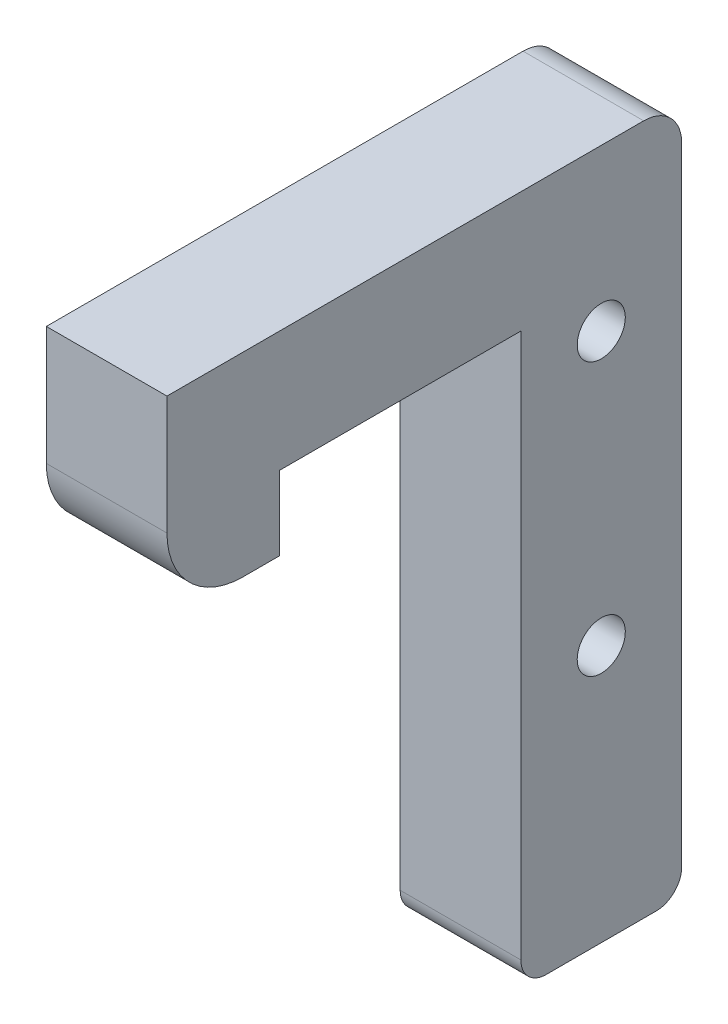
from build123d import *

# Parameters (mm, degrees)
SKETCH1_W                 = 9.525
SKETCH1_H                 = 9.525
EXTRUDE1_DEPTH            = 40.64
SKETCH3_W                 = 9.525
SKETCH3_H                 = 8.89
EXTRUDE2_DEPTH            = 5.842
FILLET1_R                 = 6
SKETCH4_W                 = 9.525
SKETCH4_H                 = 12.7
EXTRUDE3_DEPTH            = 45
FILLET2_R                 = 3
F_6_CLEARANCE_HOLE1_D     = 3.7973
F_6_CLEARANCE_HOLE1_DEPTH = 9.906
F_6_CLEARANCE_HOLE1_TIP   = 1.140824014
F_6_CLEARANCE_HOLE3_D     = 3.7973
F_6_CLEARANCE_HOLE3_DEPTH = 24.892
F_6_CLEARANCE_HOLE3_TIP   = 1.140824014
F_6_CLEARANCE_HOLE4_D     = 3.7973
F_6_CLEARANCE_HOLE4_DEPTH = 29.972
F_6_CLEARANCE_HOLE4_TIP   = 1.140824014
FILLET3_R                 = 2


with BuildPart() as part:
    # Sketch1 → Extrude1 (new body)
    with BuildSketch(Plane.XY):
        with Locations((-4.7625, 4.7625)):
            Rectangle(SKETCH1_W, SKETCH1_H)
    extrude(amount=EXTRUDE1_DEPTH)

    # Sketch3 → Extrude2 (add)
    with BuildSketch(Plane.XZ):
        with Locations((-4.7625, 36.195)):
            Rectangle(SKETCH3_W, SKETCH3_H)
    extrude(amount=EXTRUDE2_DEPTH)

    # Fillet1
    fillet1_edges = [part.edges().sort_by_distance(p)[0] for p in [
        (-4.7625, -5.842, 40.64),
    ]]
    fillet(fillet1_edges, radius=FILLET1_R)

    # Sketch4 → Extrude3 (add)
    with BuildSketch(Plane.XZ):
        with Locations((-4.7625, 6.35)):
            Rectangle(SKETCH4_W, SKETCH4_H)
    extrude(amount=EXTRUDE3_DEPTH)

    # Fillet2
    fillet2_edges = [part.edges().sort_by_distance(p)[0] for p in [
        (-4.7625, 9.525, 0),
    ]]
    fillet(fillet2_edges, radius=FILLET2_R)

    # #6 Clearance Hole1
    with Locations(Plane(origin=(0, -3.175, 6.35), x_dir=(0, 0, 1), z_dir=(1, 0, 0))):
        with Locations((0, 0)):
            Hole(F_6_CLEARANCE_HOLE1_D / 2, depth=F_6_CLEARANCE_HOLE1_DEPTH)
            with Locations((0, 0, -(F_6_CLEARANCE_HOLE1_DEPTH + F_6_CLEARANCE_HOLE1_TIP / 2))):  # 118° drill point
                Cone(0, F_6_CLEARANCE_HOLE1_D / 2, F_6_CLEARANCE_HOLE1_TIP, mode=Mode.SUBTRACT)

    # #6 Clearance Hole3
    with Locations(Plane(origin=(-4.7625, -45, 6.35), x_dir=(-1, 0, 0), z_dir=(0, -1, 0))):
        with Locations((0, 0)):
            Hole(F_6_CLEARANCE_HOLE3_D / 2, depth=F_6_CLEARANCE_HOLE3_DEPTH)
            with Locations((0, 0, -(F_6_CLEARANCE_HOLE3_DEPTH + F_6_CLEARANCE_HOLE3_TIP / 2))):  # 118° drill point
                Cone(0, F_6_CLEARANCE_HOLE3_D / 2, F_6_CLEARANCE_HOLE3_TIP, mode=Mode.SUBTRACT)

    # #6 Clearance Hole4
    with Locations(Plane(origin=(-9.525, -24.68, 6.35), x_dir=(0, 0, -1), z_dir=(-1, 0, 0))):
        with Locations((0, 0)):
            Hole(F_6_CLEARANCE_HOLE4_D / 2, depth=F_6_CLEARANCE_HOLE4_DEPTH)
            with Locations((0, 0, -(F_6_CLEARANCE_HOLE4_DEPTH + F_6_CLEARANCE_HOLE4_TIP / 2))):  # 118° drill point
                Cone(0, F_6_CLEARANCE_HOLE4_D / 2, F_6_CLEARANCE_HOLE4_TIP, mode=Mode.SUBTRACT)

    # Fillet3
    fillet3_edges = [part.edges().sort_by_distance(p)[0] for p in [
        (-4.7625, -45, 12.7),
        (-4.7625, -45, 0),
    ]]
    fillet(fillet3_edges, radius=FILLET3_R)


solid = part.part
